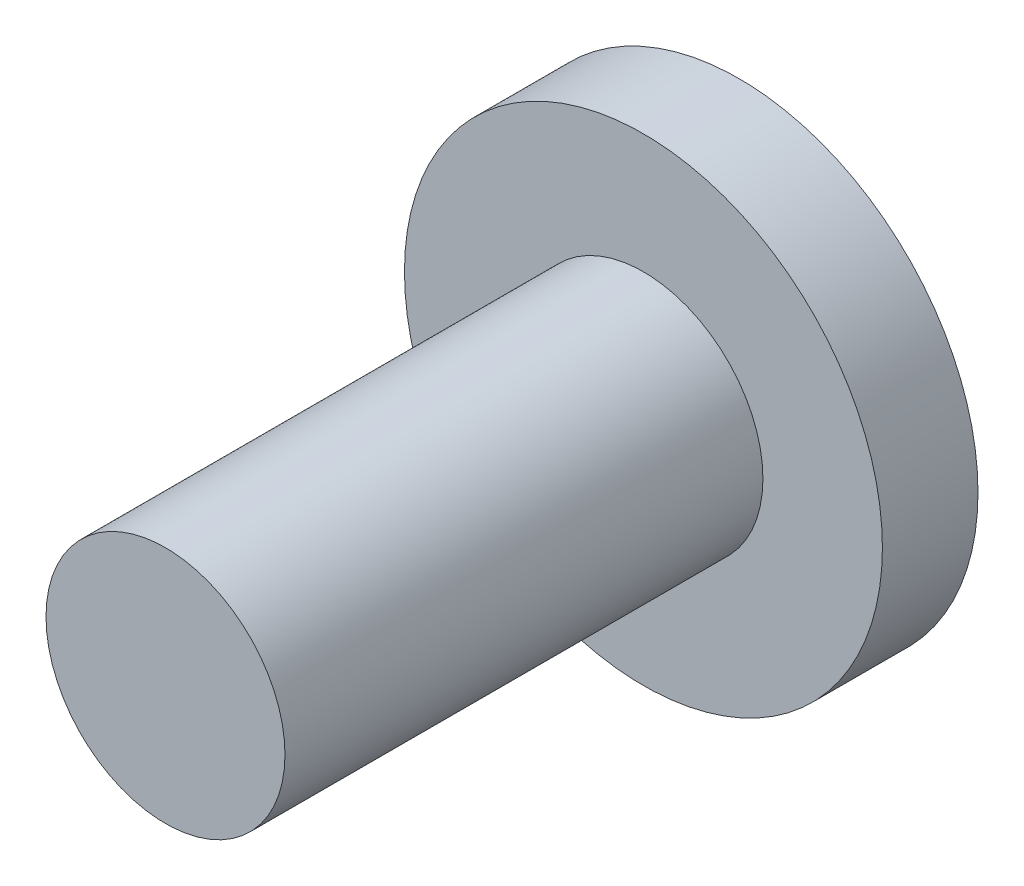
from build123d import *

# Parameters (mm, degrees)
SKETCH1_R           = 2
BOSS_EXTRUDE1_DEPTH = 0.8
SKETCH2_R           = 1
BOSS_EXTRUDE2_DEPTH = 4


with BuildPart() as part:
    # Sketch1 → Boss-Extrude1 (new body)
    with BuildSketch(Plane.XY):
        Circle(SKETCH1_R)
    extrude(amount=BOSS_EXTRUDE1_DEPTH)

    # Sketch2 → Boss-Extrude2 (add)
    with BuildSketch(Plane.XY.offset(0.8)):
        Circle(SKETCH2_R)
    extrude(amount=BOSS_EXTRUDE2_DEPTH)


solid = part.part
